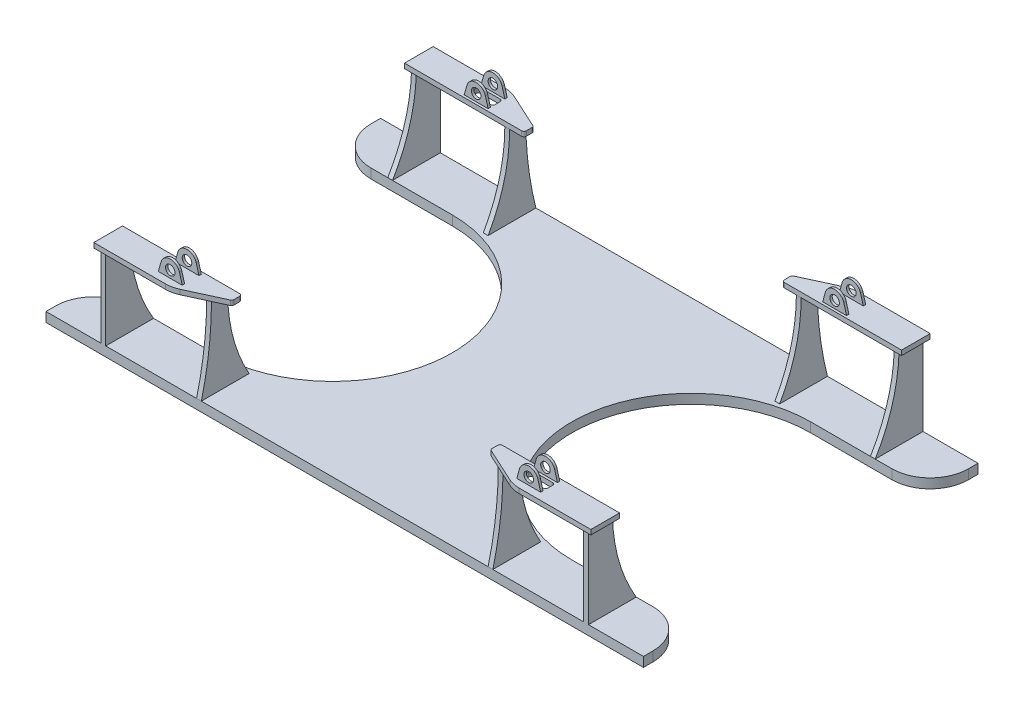
from build123d import *

# Parameters (mm, degrees)
BOSS_EXTRUDE1_DEPTH     = 5
BOSS_EXTRUDE2_START     = 250
BOSS_EXTRUDE2_DEPTH     = 5
BOSS_EXTRUDE3_DEPTH     = 5
BOSS_EXTRUDE4_DEPTH     = 5
BOSS_EXTRUDE5_START     = -2.5
SKETCH12_R              = 5
BOSS_EXTRUDE5_DEPTH     = 2.5
BOSS_EXTRUDE6_START     = -20
SKETCH12_2_R            = 5
BOSS_EXTRUDE6_DEPTH     = 2.5
MIRROR2_START           = 250
MIRROR2_COPY_1_DEPTH    = 5
MIRROR2_COPY_2_DEPTH    = 5
MIRROR2_COPY_3_DEPTH    = 5
MIRROR2_START_2         = -2.5
MIRROR2_COPY_4_SKETCH_R = 5
MIRROR2_COPY_4_DEPTH    = 2.5
MIRROR2_START_3         = -20
MIRROR2_COPY_5_SKETCH_R = 5
MIRROR2_COPY_5_DEPTH    = 2.5
SKETCH13_W              = 25
SKETCH13_H              = 10
CUT_EXTRUDE1_DEPTH      = 5
FILLET1_R               = 2.5
SKETCH15_W              = 25
SKETCH15_H              = 10
CUT_EXTRUDE2_DEPTH      = 5
FILLET2_R               = 2.5


with BuildPart() as part:
    # Sketch2 → Boss-Extrude1 (new body, symmetric)
    with BuildSketch(Plane(origin=(0, 0, 0), x_dir=(1, 0, 0), z_dir=(0, 1, 0))):
        with BuildLine():
            Line((-272.5, 125), (-187.5, 125))
            ThreePointArc((-187.5, 125), (-62.5, 0), (-187.5, -125))
            Line((-187.5, -125), (-272.5, -125))
            ThreePointArc((-272.5, -125), (-300.784271247, -136.715728753), (-312.5, -165))
            Line((-312.5, -165), (-312.5, -175))
            Line((-312.5, -175), (312.5, -175))
            Line((312.5, -175), (312.5, -165))
            ThreePointArc((312.5, -165), (300.784271247, -136.715728753), (272.5, -125))
            Line((272.5, -125), (187.5, -125))
            ThreePointArc((187.5, -125), (62.5, 0), (187.5, 125))
            Line((187.5, 125), (272.5, 125))
            ThreePointArc((272.5, 125), (300.784271247, 136.715728753), (312.5, 165))
            Line((312.5, 165), (312.5, 175))
            Line((312.5, 175), (-312.5, 175))
            Line((-312.5, 175), (-312.5, 165))
            ThreePointArc((-312.5, 165), (-300.784271247, 136.715728753), (-272.5, 125))
        make_face()
    extrude(amount=BOSS_EXTRUDE1_DEPTH, both=True)

    # Sketch5 → Boss-Extrude2 (add)
    with BuildSketch(Plane(origin=(0, 0, 0), x_dir=(0, 0, -1), z_dir=(1, 0, 0)).offset(BOSS_EXTRUDE2_START)):
        with BuildLine():
            Line((175, 5), (125, 5))
            ThreePointArc((125, 5), (143.63387523, 48.296145769), (150, 95))
            Line((150, 95), (175, 95))
            Line((175, 95), (175, 5))
        make_face()
    boss_extrude2 = extrude(amount=BOSS_EXTRUDE2_DEPTH)

    # Sketch7 → Boss-Extrude3 (add)
    with BuildSketch(Plane(origin=(0, 95, 0), x_dir=(1, 0, 0), z_dir=(0, 1, 0))):
        with BuildLine():
            Line((260, 147.5), (137.5, 147.5))
            ThreePointArc((137.5, 147.5), (135.732233047, 148.232233047), (135, 150))
            Line((135, 150), (135, 155.899029492))
            ThreePointArc((135, 155.899029492), (135.394692651, 157.247243483), (136.454144772, 158.16975335))
            Line((136.454144772, 158.16975335), (172.44973726, 174.748686302))
            ThreePointArc((172.44973726, 174.748686302), (178.575849825, 176.804100302), (185, 177.5))
            Line((185, 177.5), (260, 177.5))
            Line((260, 177.5), (260, 147.5))
        make_face()
    boss_extrude3 = extrude(amount=-BOSS_EXTRUDE3_DEPTH)

    # Sketch10 → Boss-Extrude4 (add)
    with BuildSketch(Plane.ZY.offset(-150)):
        with BuildLine():
            Line((-175, 5), (-125, 5))
            ThreePointArc((-125, 5), (-141.779773176, 46.036236512), (-147.5, 90))
            Line((-147.5, 90), (-164.408734572, 90))
            ThreePointArc((-164.408734572, 90), (-167.06674937, 47.171344571), (-175, 5))
        make_face()
    boss_extrude4 = extrude(amount=-BOSS_EXTRUDE4_DEPTH)

    # Sketch12 → Boss-Extrude5 (add)
    with BuildSketch(Plane.XY.offset(-147.5).offset(BOSS_EXTRUDE5_START)):
        with BuildLine():
            Line((175, 95), (200, 95))
            Line((200, 95), (197.12585943, 105.209765716))
            ThreePointArc((197.12585943, 105.209765716), (187.5, 112.5), (177.87414057, 105.209765716))
            Line((177.87414057, 105.209765716), (175, 95))
        make_face()
        with Locations((187.5, 102.5)):
            Circle(SKETCH12_R, mode=Mode.SUBTRACT)
    boss_extrude5 = extrude(amount=-BOSS_EXTRUDE5_DEPTH)

    # Sketch12_2 → Boss-Extrude6 (add)
    with BuildSketch(Plane.XY.offset(-147.5).offset(BOSS_EXTRUDE6_START)):
        with BuildLine():
            Line((175, 95), (200, 95))
            Line((200, 95), (197.12585943, 105.209765716))
            ThreePointArc((197.12585943, 105.209765716), (187.5, 112.5), (177.87414057, 105.209765716))
            Line((177.87414057, 105.209765716), (175, 95))
        make_face()
        with Locations((187.5, 102.5)):
            Circle(SKETCH12_2_R, mode=Mode.SUBTRACT)
    boss_extrude6 = extrude(amount=-BOSS_EXTRUDE6_DEPTH)

    # Mirror1: Boss-Extrude2, Boss-Extrude3, Boss-Extrude4, Boss-Extrude5, Boss-Extrude6 across plane
    add(boss_extrude2.mirror(Plane.XY))
    add(boss_extrude3.mirror(Plane.XY))
    add(boss_extrude4.mirror(Plane.XY))
    add(boss_extrude5.mirror(Plane.XY))
    add(boss_extrude6.mirror(Plane.XY))

    # Mirror2: Boss-Extrude2, Boss-Extrude3, Boss-Extrude4, Boss-Extrude5, Boss-Extrude6 across plane
    add(boss_extrude2.mirror(Plane(origin=(0, 0, 0), x_dir=(0, 0, 1), z_dir=(1, 0, 0))))
    add(boss_extrude3.mirror(Plane(origin=(0, 0, 0), x_dir=(0, 0, 1), z_dir=(1, 0, 0))))
    add(boss_extrude4.mirror(Plane(origin=(0, 0, 0), x_dir=(0, 0, 1), z_dir=(1, 0, 0))))
    add(boss_extrude5.mirror(Plane(origin=(0, 0, 0), x_dir=(0, 0, 1), z_dir=(1, 0, 0))))
    add(boss_extrude6.mirror(Plane(origin=(0, 0, 0), x_dir=(0, 0, 1), z_dir=(1, 0, 0))))

    # Mirror2 copy 1 sketch → Mirror2 copy 1 (add)
    with BuildSketch(Plane.ZY.offset(MIRROR2_START)):
        with BuildLine():
            Line((175, 5), (125, 5))
            ThreePointArc((125, 5), (143.63387523, 48.296145769), (150, 95))
            Line((150, 95), (175, 95))
            Line((175, 95), (175, 5))
        make_face()
    extrude(amount=MIRROR2_COPY_1_DEPTH)

    # Mirror2 copy 2 sketch → Mirror2 copy 2 (add)
    with BuildSketch(Plane(origin=(0, 95, 0), x_dir=(-1, 0, 0), z_dir=(0, 1, 0))):
        with BuildLine():
            Line((260, 147.5), (137.5, 147.5))
            ThreePointArc((137.5, 147.5), (135.732233047, 148.232233047), (135, 150))
            Line((135, 150), (135, 155.899029492))
            ThreePointArc((135, 155.899029492), (135.394692651, 157.247243483), (136.454144772, 158.16975335))
            Line((136.454144772, 158.16975335), (172.44973726, 174.748686302))
            ThreePointArc((172.44973726, 174.748686302), (178.575849825, 176.804100302), (185, 177.5))
            Line((185, 177.5), (260, 177.5))
            Line((260, 177.5), (260, 147.5))
        make_face()
    extrude(amount=-MIRROR2_COPY_2_DEPTH)

    # Mirror2 copy 3 sketch → Mirror2 copy 3 (add)
    with BuildSketch(Plane(origin=(-150, 0, 0), x_dir=(0, 0, -1), z_dir=(1, 0, 0))):
        with BuildLine():
            Line((-175, 5), (-125, 5))
            ThreePointArc((-125, 5), (-141.779773176, 46.036236512), (-147.5, 90))
            Line((-147.5, 90), (-164.408734572, 90))
            ThreePointArc((-164.408734572, 90), (-167.06674937, 47.171344571), (-175, 5))
        make_face()
    extrude(amount=-MIRROR2_COPY_3_DEPTH)

    # Mirror2 copy 4 sketch → Mirror2 copy 4 (add)
    with BuildSketch(Plane(origin=(0, 0, 147.5), x_dir=(-1, 0, 0), z_dir=(0, 0, -1)).offset(MIRROR2_START_2)):
        with BuildLine():
            Line((175, 95), (200, 95))
            Line((200, 95), (197.12585943, 105.209765716))
            ThreePointArc((197.12585943, 105.209765716), (187.5, 112.5), (177.87414057, 105.209765716))
            Line((177.87414057, 105.209765716), (175, 95))
        make_face()
        with Locations((187.5, 102.5)):
            Circle(MIRROR2_COPY_4_SKETCH_R, mode=Mode.SUBTRACT)
    extrude(amount=-MIRROR2_COPY_4_DEPTH)

    # Mirror2 copy 5 sketch → Mirror2 copy 5 (add)
    with BuildSketch(Plane(origin=(0, 0, 147.5), x_dir=(-1, 0, 0), z_dir=(0, 0, -1)).offset(MIRROR2_START_3)):
        with BuildLine():
            Line((175, 95), (200, 95))
            Line((200, 95), (197.12585943, 105.209765716))
            ThreePointArc((197.12585943, 105.209765716), (187.5, 112.5), (177.87414057, 105.209765716))
            Line((177.87414057, 105.209765716), (175, 95))
        make_face()
        with Locations((187.5, 102.5)):
            Circle(MIRROR2_COPY_5_SKETCH_R, mode=Mode.SUBTRACT)
    extrude(amount=-MIRROR2_COPY_5_DEPTH)

    # Sketch13 → Cut-Extrude1 (cut)
    with BuildSketch(Plane(origin=(0, 95, 0), x_dir=(1, 0, 0), z_dir=(0, 1, 0))):
        with Locations((187.5, -160)):
            Rectangle(SKETCH13_W, SKETCH13_H)
    extrude(amount=-CUT_EXTRUDE1_DEPTH, mode=Mode.SUBTRACT)

    # Fillet1
    fillet1_edges = [part.edges().sort_by_distance(p)[0] for p in [
        (200, 92.5, 155),
        (200, 92.5, 165),
        (175, 92.5, 165),
        (175, 92.5, 155),
    ]]
    fillet(fillet1_edges, radius=FILLET1_R)

    # Sketch15 → Cut-Extrude2 (cut)
    with BuildSketch(Plane(origin=(0, 95, 0), x_dir=(1, 0, 0), z_dir=(0, 1, 0))):
        with Locations((-187.5, 160)):
            Rectangle(SKETCH15_W, SKETCH15_H)
    extrude(amount=-CUT_EXTRUDE2_DEPTH, mode=Mode.SUBTRACT)

    # Fillet2
    fillet2_edges = [part.edges().sort_by_distance(p)[0] for p in [
        (-200, 92.5, -155),
        (-200, 92.5, -165),
        (-175, 92.5, -165),
        (-175, 92.5, -155),
    ]]
    fillet(fillet2_edges, radius=FILLET2_R)


solid = part.part
